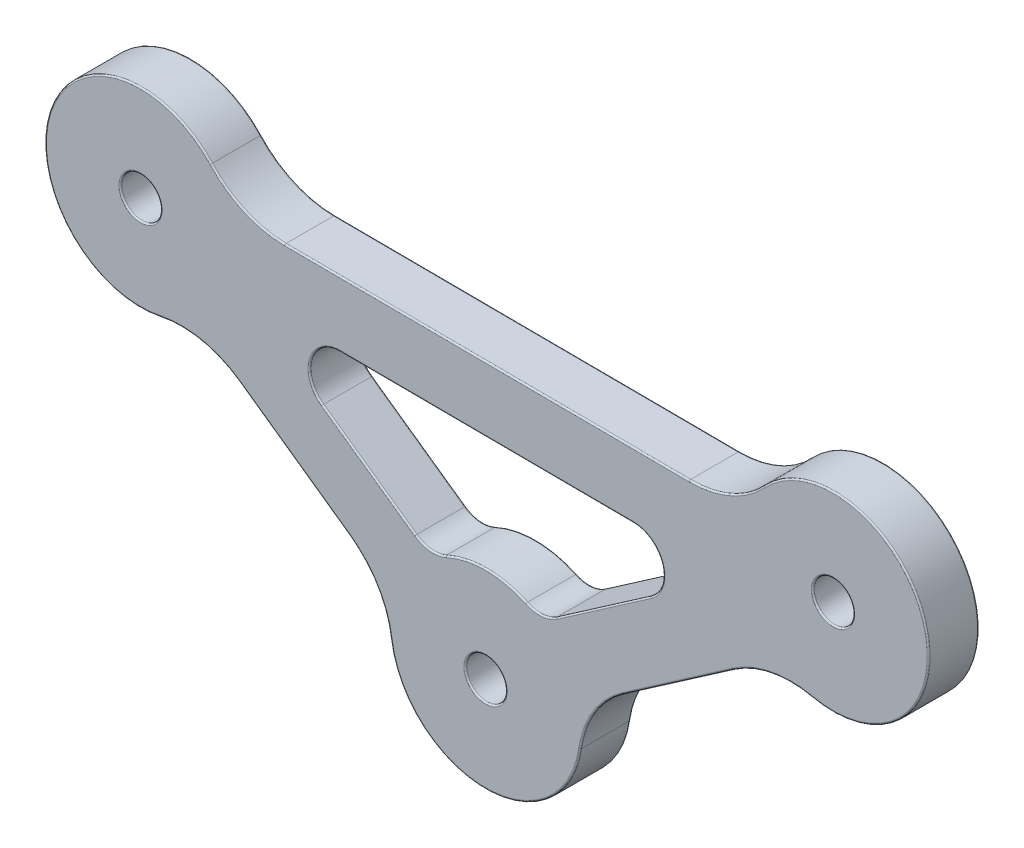
from build123d import *

# Parameters (mm, degrees)
SKETCH1_R             = 9.5
SKETCH1_R_2           = 2
BOSS_EXTRUDE1_DEPTH   = 5
BOSS_EXTRUDE1_2_DEPTH = 5
BOSS_EXTRUDE1_3_DEPTH = 5
EXTRUDE_THIN1_DEPTH   = 5
FILLET1_R             = 3
FILLET2_R             = 10
FILLET3_R             = 0.15


with BuildPart() as part:
    # Sketch1 → Boss-Extrude1 (new body)
    with BuildSketch(Plane.XY):
        with Locations((-71.352572296, 303.213089234)):
            Circle(SKETCH1_R)
        with Locations((-71.352572296, 303.213089234)):
            Circle(SKETCH1_R_2, mode=Mode.SUBTRACT)
    extrude(amount=-BOSS_EXTRUDE1_DEPTH)



with BuildPart() as body_2:
    # Sketch1 → Boss-Extrude1 2 (new body)
    with BuildSketch(Plane.XY):
        with Locations((-37.077654746, 278.93902845)):
            Circle(SKETCH1_R)
        with Locations((-37.077654746, 278.93902845)):
            Circle(SKETCH1_R_2, mode=Mode.SUBTRACT)
    extrude(amount=-BOSS_EXTRUDE1_2_DEPTH)


with BuildPart() as body_3:
    # Sketch1 → Boss-Extrude1 3 (new body)
    with BuildSketch(Plane.XY):
        with Locations((-2.544786738, 302.844697802)):
            Circle(SKETCH1_R)
        with Locations((-2.544786738, 302.844697802)):
            Circle(SKETCH1_R_2, mode=Mode.SUBTRACT)
    extrude(amount=-BOSS_EXTRUDE1_3_DEPTH)


with BuildPart() as part_1:
    add(part.part)

    add(body_2.part)  # Extrude-Thin1 merges body 2

    add(body_3.part)  # Extrude-Thin1 merges body 3
    # Sketch2 → Extrude-Thin1 (add)
    with BuildSketch(Plane.XY):
        Polygon((-68.334505444, 297.093140502), (-43.85242148, 279.754525657), (-40.095721597, 285.058977182), (-64.577805561, 302.397592028), align=None)
        Polygon((-64.46607951, 299.926172918), (-9.46607951, 299.631707276), (-9.431279524, 306.131614118), (-64.431279524, 306.42607976), align=None)
        Polygon((-9.327897058, 302.101788395), (-33.994231349, 285.026310287), (-30.294544426, 279.681937857), (-5.628210134, 296.757415965), align=None)
    extrude(amount=-EXTRUDE_THIN1_DEPTH)

    # Fillet1
    fillet1_edges = [part_1.edges().sort_by_distance(p)[0] for p in [
        (-42.484181905, 286.750524087, -2.5),
        (-61.06243691, 299.907950085, -2.5),
        (-12.86972211, 299.649930108, -2.5),
        (-31.587795668, 286.692185698, -2.5),
    ]]
    fillet(fillet1_edges, radius=FILLET1_R)

    # Fillet2
    fillet2_edges = [part_1.edges().sort_by_distance(p)[0] for p in [
        (-65.946045137, 295.401593597, -2.5),
        (-46.240881788, 281.446072561, -2.5),
        (-62.408514705, 306.415250038, -2.5),
        (-11.454044342, 306.142443841, -2.5),
        (-8.034645815, 295.091540554, -2.5),
        (-27.888108745, 281.347813269, -2.5),
    ]]
    fillet(fillet2_edges, radius=FILLET2_R)

    # Fillet3
    fillet3_edges = [part_1.edges().sort_by_distance(p)[0] for p in [
        (-48.665613897, 291.128315972, -5),
        (-48.665613897, 291.128315972, 0),
        (-36.96607951, 299.778940097, 0),
        (-36.96607951, 299.778940097, -5),
        (-25.359842683, 291.003538719, -5),
        (-25.359842683, 291.003538719, 0),
        (-37.026793227, 288.438892297, -5),
        (-37.026793227, 288.438892297, 0),
        (-54.420130451, 297.774475034, 0),
        (-54.420130451, 297.774475034, -5),
        (-19.534492041, 297.58770009, -5),
        (-19.534492041, 297.58770009, 0),
        (-31.488886236, 287.249489404, 0),
        (-31.488886236, 287.249489404, -5),
        (-42.577118318, 287.30885492, -5),
        (-42.577118318, 287.30885492, 0),
        (-37.128516264, 269.439164604, -5),
        (-37.128516264, 269.439164604, 0),
        (-56.093463462, 288.423833079, 0),
        (-56.093463462, 288.423833079, -5),
        (-80.397459123, 306.118260879, 0),
        (-80.397459123, 306.118260879, -5),
        (-17.96137728, 288.219676911, -5),
        (-17.96137728, 288.219676911, 0),
        (6.530688796, 305.652854463, 0),
        (6.530688796, 305.652854463, -5),
        (-36.931279524, 306.278846939, 0),
        (-36.931279524, 306.278846939, -5),
        (-47.847852179, 281.559429504, -5),
        (-47.847852179, 281.559429504, 0),
        (-65.305699691, 293.923364473, -5),
        (-65.305699691, 293.923364473, 0),
        (-26.280016704, 281.443957022, 0),
        (-26.280016704, 281.443957022, -5),
        (-8.690782741, 293.620252694, -5),
        (-8.690782741, 293.620252694, 0),
        (-12.826462016, 306.986051191, -5),
        (-12.826462016, 306.986051191, 0),
        (-61.027142753, 307.244113816, -5),
        (-61.027142753, 307.244113816, 0),
        (-39.077654746, 278.93902845, -5),
        (-39.077654746, 278.93902845, 0),
        (-73.352572296, 303.213089234, -5),
        (-73.352572296, 303.213089234, 0),
        (-4.544786738, 302.844697802, -5),
        (-4.544786738, 302.844697802, 0),
    ]]
    fillet(fillet3_edges, radius=FILLET3_R)


solid = part_1.part
